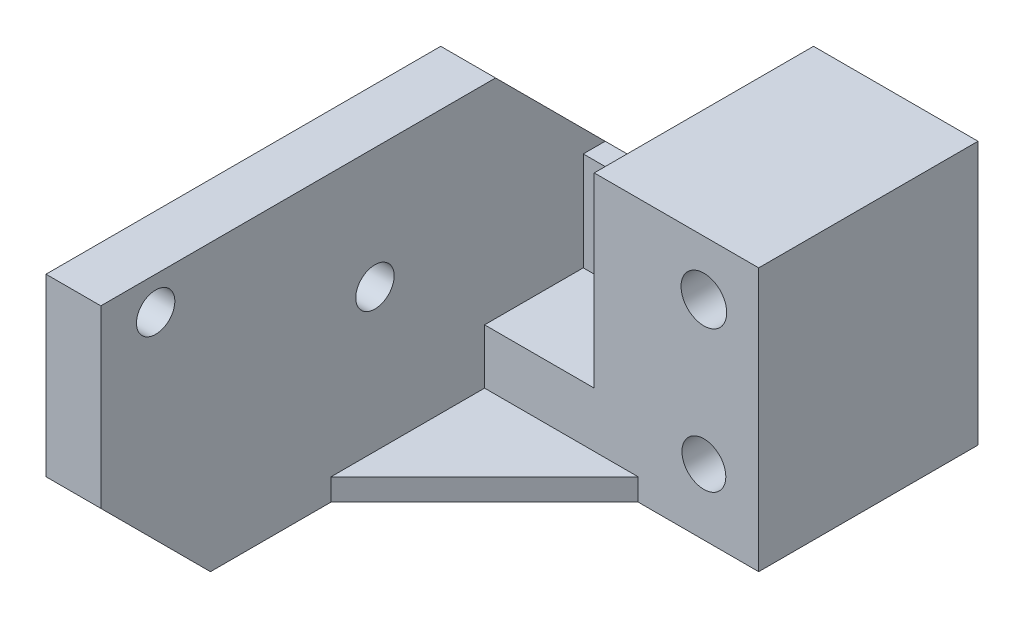
from build123d import *

# Parameters (mm, degrees)
EXTRUDE_1_DEPTH     = 12
CUT_EXTRUDE_1_REACH = 22
SKETCH_2_R          = 2
SKETCH_3_W          = 46
SKETCH_3_H          = 26
SKETCH_3_R          = 1.75
EXTRUDE_2_DEPTH     = 5
CHAMFER_1_SIZE      = 10
EXTRUDE_3_DEPTH     = 2
CHAMFER_2_SIZE      = 10
SKETCH_5_W          = 15
SKETCH_5_H          = 20
EXTRUDE_4_DEPTH     = 12
SKETCH_6_R          = 2.084127943
CUT_EXTRUDE_2_DEPTH = 21
SKETCH_7_W          = 10
SKETCH_7_H          = 5
CUT_EXTRUDE_3_DEPTH = 47
SKETCH_8_W          = 10
SKETCH_8_H          = 9
EXTRUDE_5_DEPTH     = 2
CHAMFER_3_SIZE      = 4


with BuildPart() as part:
    # Эскиз1 → Бобышка-Вытянуть1 (new body)
    with BuildSketch(Plane(origin=(0, 0, 0), x_dir=(1, 0, 0), z_dir=(0, 1, 0))):
        Polygon((0, 0), (0, 11), (15, 11), (15, 20), (30, 20), (30, 0), align=None)
    extrude(amount=EXTRUDE_1_DEPTH)

    # Эскиз2 → Вырез-Вытянуть1 (cut, up to next)
    with BuildSketch(Plane.XY, mode=Mode.PRIVATE) as cut_extrude_1_sk1:
        with Locations((25, 6)):
            Circle(SKETCH_2_R)
    cut_extrude_1_tool1 = extrude(cut_extrude_1_sk1.sketch, amount=-CUT_EXTRUDE_1_REACH, mode=Mode.PRIVATE) & part.part
    add(cut_extrude_1_tool1.solids().sort_by_distance((25, 6, 0))[0], mode=Mode.SUBTRACT)

    # Эскиз3 → Бобышка-Вытянуть2 (add)
    with BuildSketch(Plane.ZY):
        with Locations((12, 13)):
            Rectangle(SKETCH_3_W, SKETCH_3_H)
        with Locations((30, 23)):
            Circle(SKETCH_3_R, mode=Mode.SUBTRACT)
        with Locations((10, 15)):
            Circle(SKETCH_3_R, mode=Mode.SUBTRACT)
    extrude(amount=-EXTRUDE_2_DEPTH)

    # Фаска1
    chamfer_1_edges = [part.edges().sort_by_distance(p)[0] for p in [
        (2.5, 26, -11),
    ]]
    chamfer(chamfer_1_edges, length=CHAMFER_1_SIZE)

    # Эскиз4 → Бобышка-Вытянуть3 (add)
    with BuildSketch(Plane.XZ):
        Polygon((5, 14), (19, 0), (5, 0), align=None)
    extrude(amount=-EXTRUDE_3_DEPTH)

    # Фаска2
    chamfer_2_edges = [part.edges().sort_by_distance(p)[0] for p in [
        (2.5, 0, 35),
    ]]
    chamfer(chamfer_2_edges, length=CHAMFER_2_SIZE)

    # Эскиз5 → Бобышка-Вытянуть4 (add)
    with BuildSketch(Plane(origin=(0, 12, 0), x_dir=(1, 0, 0), z_dir=(0, 1, 0))):
        with Locations((22.5, 10)):
            Rectangle(SKETCH_5_W, SKETCH_5_H)
    extrude(amount=EXTRUDE_4_DEPTH)

    # Эскиз6 → Вырез-Вытянуть2 (cut, through all)
    with BuildSketch(Plane.XY):
        with Locations((25, 19)):
            Circle(SKETCH_6_R)
    extrude(amount=-CUT_EXTRUDE_2_DEPTH, mode=Mode.SUBTRACT)

    # Эскиз7 → Вырез-Вытянуть3 (cut, through all)
    with BuildSketch(Plane(origin=(0, 0, -11), x_dir=(-1, 0, 0), z_dir=(0, 0, -1))):
        with Locations((-10, 9.5)):
            Rectangle(SKETCH_7_W, SKETCH_7_H)
    extrude(amount=-CUT_EXTRUDE_3_DEPTH, mode=Mode.SUBTRACT)

    # Эскиз8 → Бобышка-Вытянуть5 (add)
    with BuildSketch(Plane(origin=(0, 0, -11), x_dir=(-1, 0, 0), z_dir=(0, 0, -1))):
        with Locations((-10, 11.5)):
            Rectangle(SKETCH_8_W, SKETCH_8_H)
    extrude(amount=-EXTRUDE_5_DEPTH)

    # Фаска3
    chamfer_3_edges = [part.edges().sort_by_distance(p)[0] for p in [
        (0, 8, -11),
        (7.5, 0, -11),
    ]]
    chamfer(chamfer_3_edges, length=CHAMFER_3_SIZE)


solid = part.part
